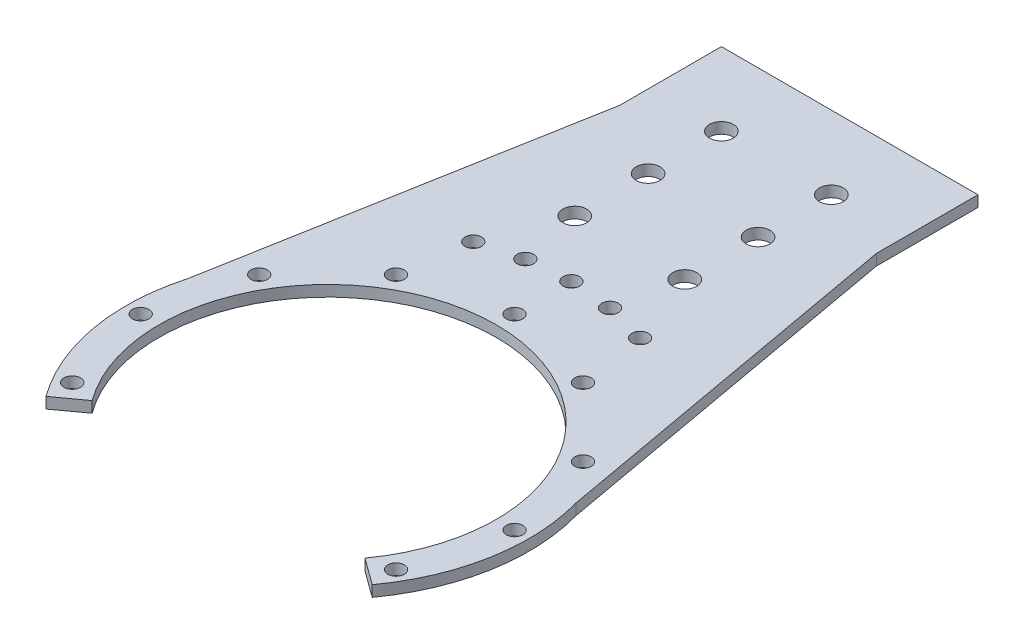
from build123d import *

# Parameters (mm, degrees)
SKETCH1_R                       = 55
BOSS_EXTRUDE1_DEPTH             = 3
SKETCH2_W                       = 70
SKETCH2_H                       = 100
BOSS_EXTRUDE2_DEPTH             = 3
BOSS_EXTRUDE3_DEPTH             = 3
SKETCH4_R                       = 46
CUT_EXTRUDE2_DEPTH              = 1
CUT_EXTRUDE2_DEPTH_BACK         = 4
CUT_EXTRUDE5_START              = -4
CUT_EXTRUDE5_DEPTH              = 5
CUT_EXTRUDE3_START              = -4
SKETCH5_R                       = 2.25
CUT_EXTRUDE3_DEPTH              = 5
CIRPATTERN1_COUNT               = 12
CUT_EXTRUDE4_START              = -4
SKETCH6_R                       = 3.25
CUT_EXTRUDE4_DEPTH              = 5
LPATTERN1_COUNT                 = 3
LPATTERN1_PITCH                 = 20
CUT_EXTRUDE6_START              = -1
SKETCH8_R                       = 2.25
CUT_EXTRUDE6_DEPTH              = 5
CIRPATTERN2_COUNT               = 3
CIRPATTERN2_ANGLE               = 20
CIRPATTERN2_THE_OTHER_WAY_COUNT = 3
CIRPATTERN2_THE_OTHER_WAY_ANGLE = 20


with BuildPart() as part:
    # Sketch1 → Boss-Extrude1 (new body)
    with BuildSketch(Plane(origin=(0, 0, 0), x_dir=(1, 0, 0), z_dir=(0, 1, 0))):
        Circle(SKETCH1_R)
    extrude(amount=BOSS_EXTRUDE1_DEPTH)

    # Sketch2 → Boss-Extrude2 (add)
    with BuildSketch(Plane(origin=(0, 0, 0), x_dir=(1, 0, 0), z_dir=(0, 1, 0))):
        with Locations((0, 92.426406871)):
            Rectangle(SKETCH2_W, SKETCH2_H)
    extrude(amount=BOSS_EXTRUDE2_DEPTH)

    # Sketch9 → Boss-Extrude3 (add)
    with BuildSketch(Plane(origin=(0, 0, 0), x_dir=(1, 0, 0), z_dir=(0, 1, 0))):
        Polygon((-35, 114.721305974), (-52.984880526, 14.751353687), (-17.871452142, 14.751353687), align=None)
    boss_extrude3 = extrude(amount=BOSS_EXTRUDE3_DEPTH)

    # Mirror2: Boss-Extrude3 across plane
    add(boss_extrude3.mirror(Plane(origin=(0, 0, 0), x_dir=(0, 0, 1), z_dir=(1, 0, 0))))

    # Sketch4 → Cut-Extrude2 (cut, two sides)
    with BuildSketch(Plane(origin=(0, 3, 0), x_dir=(1, 0, 0), z_dir=(0, 1, 0))) as cut_extrude2_sk:
        Circle(SKETCH4_R)
    extrude(amount=CUT_EXTRUDE2_DEPTH, mode=Mode.SUBTRACT)
    extrude(cut_extrude2_sk.sketch, amount=-CUT_EXTRUDE2_DEPTH_BACK, mode=Mode.SUBTRACT)

    # Sketch7 → Cut-Extrude5 (cut)
    with BuildSketch(Plane(origin=(0, 3, 0), x_dir=(1, 0, 0), z_dir=(0, 1, 0)).offset(CUT_EXTRUDE5_START)):
        with BuildLine():
            Line((0, 0), (0, -55))
            ThreePointArc((0, -55), (-24.969477486, -49.00535883), (-44.495934691, -32.328188876))
            Line((-44.495934691, -32.328188876), (0, 0))
        make_face()
    cut_extrude5 = extrude(amount=CUT_EXTRUDE5_DEPTH, mode=Mode.SUBTRACT)

    # Mirror1: Cut-Extrude5 across plane
    add(cut_extrude5.mirror(Plane(origin=(0, 0, 0), x_dir=(0, 0, 1), z_dir=(1, 0, 0))), mode=Mode.SUBTRACT)

    # Sketch5 → Cut-Extrude3 (cut)
    with BuildSketch(Plane(origin=(0, 3, 0), x_dir=(1, 0, 0), z_dir=(0, 1, 0)).offset(CUT_EXTRUDE3_START)):
        with Locations((0, 51)):
            Circle(SKETCH5_R)
    cut_extrude3 = extrude(amount=CUT_EXTRUDE3_DEPTH, mode=Mode.SUBTRACT)

    # CirPattern1: Cut-Extrude3 ×12 about axis
    cirpattern1_axis = Axis((0, 0, 0), (0, 1, 0))
    for i in range(1, CIRPATTERN1_COUNT):
        add(cut_extrude3.rotate(cirpattern1_axis, i * 360 / CIRPATTERN1_COUNT), mode=Mode.SUBTRACT)

    # Sketch6 → Cut-Extrude4 (cut)
    with BuildSketch(Plane(origin=(0, 3, 0), x_dir=(1, 0, 0), z_dir=(0, 1, 0)).offset(CUT_EXTRUDE4_START)):
        with Locations((15, 122.426406871)):
            Circle(SKETCH6_R)
        with Locations((-15, 122.426406871)):
            Circle(SKETCH6_R)
    cut_extrude4 = extrude(amount=CUT_EXTRUDE4_DEPTH, mode=Mode.SUBTRACT)

    # LPattern1: Cut-Extrude4 ×3
    with Locations(*[(0, 0, i * LPATTERN1_PITCH) for i in range(1, LPATTERN1_COUNT)]):
        add(cut_extrude4, mode=Mode.SUBTRACT)

    # Sketch8 → Cut-Extrude6 (cut)
    with BuildSketch(Plane(origin=(0, 0, 0), x_dir=(1, 0, 0), z_dir=(0, 1, 0)).offset(CUT_EXTRUDE6_START)):
        with Locations((0, 66.5)):
            Circle(SKETCH8_R)
    cut_extrude6 = extrude(amount=CUT_EXTRUDE6_DEPTH, mode=Mode.SUBTRACT)

    # CirPattern2: Cut-Extrude6 ×3 about axis
    cirpattern2_axis = Axis((0, 0, 0), (0, 1, 0))
    for i in range(1, CIRPATTERN2_COUNT):
        add(cut_extrude6.rotate(cirpattern2_axis, i * CIRPATTERN2_ANGLE / (CIRPATTERN2_COUNT - 1)), mode=Mode.SUBTRACT)

    # CirPattern2 the other way: Cut-Extrude6 ×3 about axis
    cirpattern2_the_other_way_axis = Axis((0, 0, 0), (0, -1, 0))
    for i in range(1, CIRPATTERN2_THE_OTHER_WAY_COUNT):
        add(cut_extrude6.rotate(cirpattern2_the_other_way_axis, i * CIRPATTERN2_THE_OTHER_WAY_ANGLE / (CIRPATTERN2_THE_OTHER_WAY_COUNT - 1)), mode=Mode.SUBTRACT)


solid = part.part
